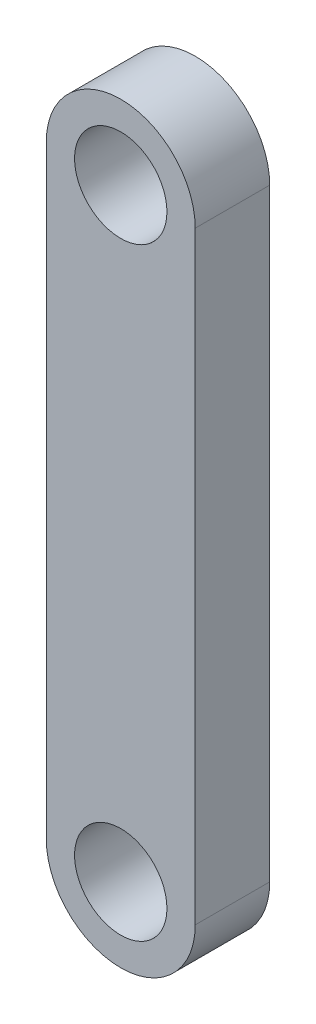
from build123d import *

# Parameters (mm, degrees)
SKETCH1_R           = 3.937
BOSS_EXTRUDE1_DEPTH = 6.35


with BuildPart() as part:
    # Sketch1 → Boss-Extrude1 (new body)
    with BuildSketch(Plane.XY):
        with BuildLine():
            Line((6.35, 38.075002032), (6.35, -13.359997968))
            ThreePointArc((6.35, -13.359997968), (0, -19.709997968), (-6.35, -13.359997968))
            Line((-6.35, -13.359997968), (-6.35, 38.075002032))
            ThreePointArc((-6.35, 38.075002032), (0, 44.425002032), (6.35, 38.075002032))
        make_face()
        with Locations((0, 38.075002032)):
            Circle(SKETCH1_R, mode=Mode.SUBTRACT)
        with Locations((0, -13.359997968)):
            Circle(SKETCH1_R, mode=Mode.SUBTRACT)
    extrude(amount=BOSS_EXTRUDE1_DEPTH)


solid = part.part
